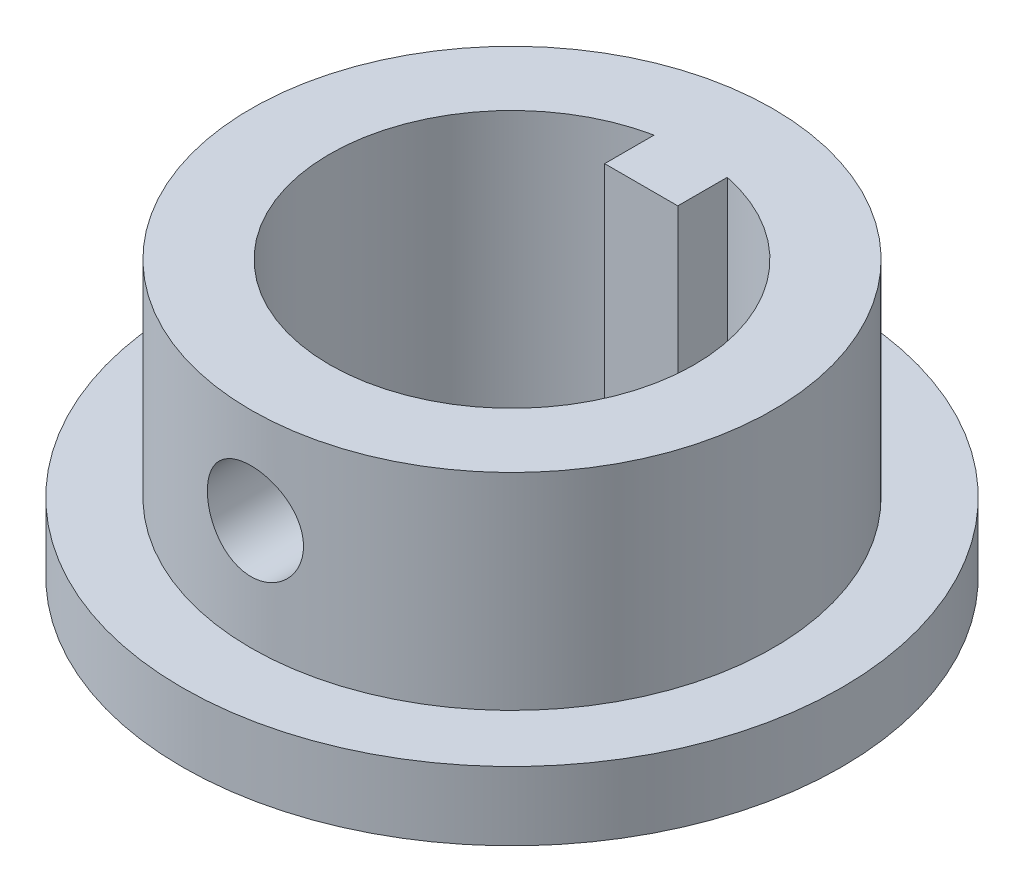
from build123d import *

# Parameters (mm, degrees)
SKETCH1_R           = 9.5
BOSS_EXTRUDE1_DEPTH = 10
SKETCH2_R           = 12
BOSS_EXTRUDE2_DEPTH = 2.5
CUT_EXTRUDE2_DEPTH  = 2.5
SKETCH5_R           = 1.75
CUT_EXTRUDE3_DEPTH  = 15


with BuildPart() as part:
    # Sketch1 → Boss-Extrude1 (new body)
    with BuildSketch(Plane(origin=(0, 0, 0), x_dir=(1, 0, 0), z_dir=(0, 1, 0))):
        Circle(SKETCH1_R)
        with BuildLine():
            Line((-1.332, 6.504006227), (-1.332, 4.704006227))
            Line((-1.332, 4.704006227), (1.33, 4.704006227))
            Line((1.33, 4.704006227), (1.33, 6.5044155))
            ThreePointArc((1.33, 6.5044155), (0.001020723, -6.638999922), (-1.332, 6.504006227))
        make_face(mode=Mode.SUBTRACT)
    extrude(amount=BOSS_EXTRUDE1_DEPTH)

    # Sketch2 → Boss-Extrude2 (add)
    with BuildSketch(Plane.XZ):
        Circle(SKETCH2_R)
    extrude(amount=-BOSS_EXTRUDE2_DEPTH)

    # Sketch4 → Cut-Extrude2 (cut)
    with BuildSketch(Plane(origin=(0, 2.5, 0), x_dir=(1, 0, 0), z_dir=(0, 1, 0))):
        with BuildLine():
            Line((-1.332, 4.704006227), (1.33, 4.704006227))
            Line((1.33, 4.704006227), (1.33, 6.5044155))
            ThreePointArc((1.33, 6.5044155), (0.001020723, -6.638999922), (-1.332, 6.504006227))
            Line((-1.332, 6.504006227), (-1.332, 4.704006227))
        make_face()
    extrude(amount=-CUT_EXTRUDE2_DEPTH, mode=Mode.SUBTRACT)

    # Sketch5 → Cut-Extrude3 (cut)
    with BuildSketch(Plane.XY.offset(-4.704006227)):
        with Locations((-0.000110737, 6.499999939)):
            Circle(SKETCH5_R)
    extrude(amount=CUT_EXTRUDE3_DEPTH, mode=Mode.SUBTRACT)


solid = part.part
